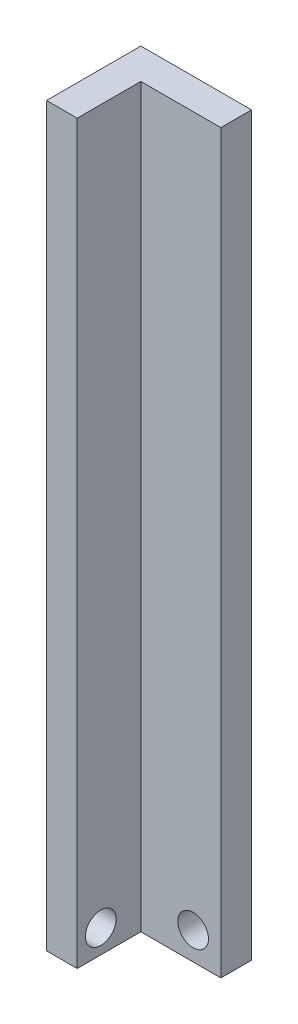
from build123d import *

# Parameters (mm, degrees)
BOSS_EXTRUDE1_DEPTH = 304.8
CUT_EXTRUDE1_DEPTH  = 12.7
SKETCH3_R           = 6.35
CUT_EXTRUDE2_DEPTH  = 12.7


with BuildPart() as part:
    # Sketch1 → Boss-Extrude1 (new body)
    with BuildSketch(Plane(origin=(0, 0, 0), x_dir=(1, 0, 0), z_dir=(0, 1, 0))):
        Polygon((-76.143480967, 44.082766217), (-63.443480967, 44.082766217), (-63.443480967, 70.416025302), (-30.342534375, 70.416025302), (-30.342534375, 83.116025302), (-76.143480967, 83.116025302), align=None)
    extrude(amount=BOSS_EXTRUDE1_DEPTH)

    # Sketch2 → Cut-Extrude1 (cut)
    with BuildSketch(Plane(origin=(0, 0, -83.116025302), x_dir=(-1, 0, 0), z_dir=(0, 0, -1))):
        with BuildLine():
            ThreePointArc((48.142771023, 11.450236648), (41.792771023, 17.800236648), (35.442771023, 11.450236648))
            Line((35.442771023, 11.450236648), (48.142771023, 11.450236648))
        make_face()
        with BuildLine():
            Line((48.142771023, 11.450236648), (35.442771023, 11.450236648))
            ThreePointArc((35.442771023, 11.450236648), (41.792771023, 5.100236648), (48.142771023, 11.450236648))
        make_face()
    extrude(amount=-CUT_EXTRUDE1_DEPTH, mode=Mode.SUBTRACT)

    # Sketch3 → Cut-Extrude2 (cut)
    with BuildSketch(Plane.ZY.offset(76.143480967)):
        with Locations((-53.841080989, 9.758314771)):
            Circle(SKETCH3_R)
    extrude(amount=-CUT_EXTRUDE2_DEPTH, mode=Mode.SUBTRACT)


solid = part.part
